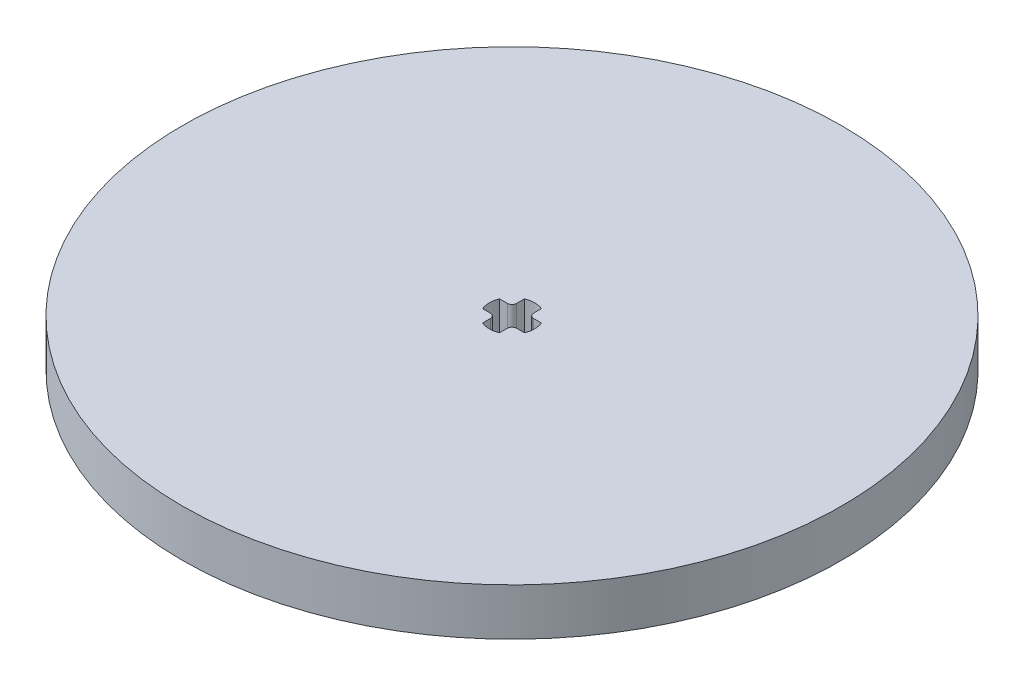
from build123d import *

# Parameters (mm, degrees)
SKETCH1_R           = 35
BOSS_EXTRUDE1_DEPTH = 5


with BuildPart() as part:
    # Sketch1 → Boss-Extrude1 (new body)
    with BuildSketch(Plane(origin=(0, 0, 0), x_dir=(1, 0, 0), z_dir=(0, 1, 0))):
        Circle(SKETCH1_R)
        with BuildLine():
            Line((-1.4, 0.9), (-2.224859546, 0.9))
            ThreePointArc((-2.224859546, 0.9), (-2.4, 0), (-2.224859546, -0.9))
            Line((-2.224859546, -0.9), (-1.4, -0.9))
            ThreePointArc((-1.4, -0.9), (-1.046446609, -1.046446609), (-0.9, -1.4))
            Line((-0.9, -1.4), (-0.9, -2.224859546))
            ThreePointArc((-0.9, -2.224859546), (0, -2.4), (0.9, -2.224859546))
            Line((0.9, -2.224859546), (0.9, -1.4))
            ThreePointArc((0.9, -1.4), (1.046446609, -1.046446609), (1.4, -0.9))
            Line((1.4, -0.9), (2.224859546, -0.9))
            ThreePointArc((2.224859546, -0.9), (2.4, 0), (2.224859546, 0.9))
            Line((2.224859546, 0.9), (1.4, 0.9))
            ThreePointArc((1.4, 0.9), (1.046446609, 1.046446609), (0.9, 1.4))
            Line((0.9, 1.4), (0.9, 2.224859546))
            ThreePointArc((0.9, 2.224859546), (0, 2.4), (-0.9, 2.224859546))
            Line((-0.9, 2.224859546), (-0.9, 1.4))
            ThreePointArc((-0.9, 1.4), (-1.046446609, 1.046446609), (-1.4, 0.9))
        make_face(mode=Mode.SUBTRACT)
    extrude(amount=BOSS_EXTRUDE1_DEPTH)


solid = part.part
